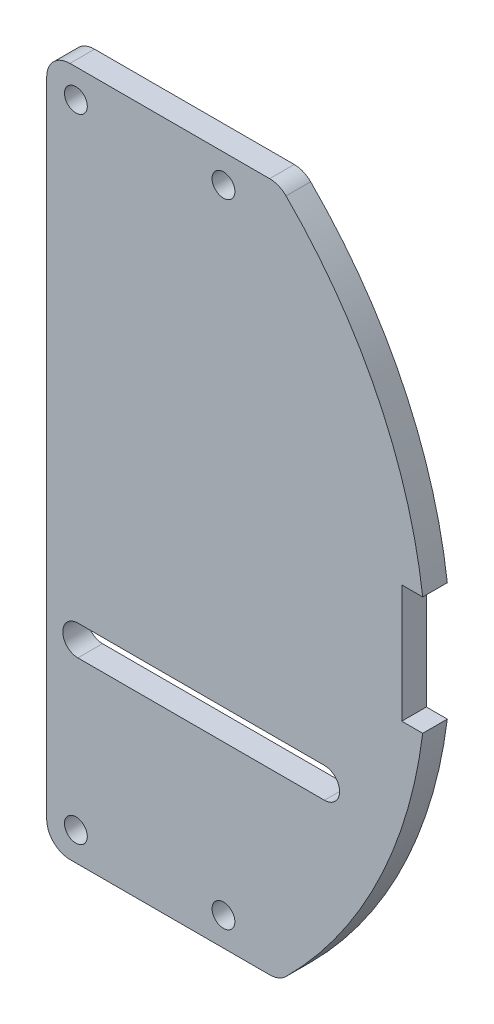
from build123d import *

# Parameters (mm, degrees)
BOSS_EXTRUDE1_DEPTH = 3.175
SKETCH2_R           = 1.4732
CUT_EXTRUDE1_DEPTH  = 4.175
CUT_EXTRUDE2_DEPTH  = 4.175
FILLET1_R           = 3
CUT_EXTRUDE5_DEPTH  = 4.175


with BuildPart() as part:
    # Sketch1 → Boss-Extrude1 (new body)
    with BuildSketch(Plane.XY):
        with BuildLine():
            Line((12.587486719, 44.5), (42.587486719, 44.5))
            ThreePointArc((42.587486719, 44.5), (61.594999998, 0), (42.587486719, -44.5))
            Line((42.587486719, -44.5), (12.587486719, -44.5))
            Line((12.587486719, -44.5), (12.587486719, 44.5))
        make_face()
    extrude(amount=BOSS_EXTRUDE1_DEPTH)

    # Sketch2 → Cut-Extrude1 (cut, through all)
    with BuildSketch(Plane.XY.offset(3.175)):
        with Locations((16.354311186, -40.81189221)):
            Circle(SKETCH2_R)
        with Locations((35.404311186, -40.81189221)):
            Circle(SKETCH2_R)
        with Locations((16.354311186, 40.81189221)):
            Circle(SKETCH2_R)
        with Locations((35.404311186, 40.81189221)):
            Circle(SKETCH2_R)
    extrude(amount=-CUT_EXTRUDE1_DEPTH, mode=Mode.SUBTRACT)

    # Sketch3 → Cut-Extrude2 (cut, through all)
    with BuildSketch(Plane.XY.offset(3.175)):
        with BuildLine():
            Line((58.42, 7.62), (61.121842452, 7.62))
            ThreePointArc((61.121842452, 7.62), (61.594999998, 0), (61.121842452, -7.62))
            Line((61.121842452, -7.62), (58.42, -7.62))
            Line((58.42, -7.62), (58.42, 7.62))
        make_face()
    extrude(amount=-CUT_EXTRUDE2_DEPTH, mode=Mode.SUBTRACT)

    # Fillet1
    fillet1_edges = [part.edges().sort_by_distance(p)[0] for p in [
        (12.587486719, 44.5, 1.5875),
        (42.587486719, 44.5, 1.5875),
        (42.587486719, -44.5, 1.5875),
        (12.587486719, -44.5, 1.5875),
    ]]
    fillet(fillet1_edges, radius=FILLET1_R)

    # Sketch5 → Cut-Extrude5 (cut, through all)
    with BuildSketch(Plane.XY.offset(3.175)):
        with BuildLine():
            Line((16.612162061, -17.554236987), (48.444763602, -17.554236987))
            ThreePointArc((48.444763602, -17.554236987), (50.390526615, -19.5), (48.444763602, -21.445763013))
            Line((48.444763602, -21.445763013), (16.612162061, -21.445763013))
            ThreePointArc((16.612162061, -21.445763013), (14.666399048, -19.5), (16.612162061, -17.554236987))
        make_face()
    extrude(amount=-CUT_EXTRUDE5_DEPTH, mode=Mode.SUBTRACT)


solid = part.part
